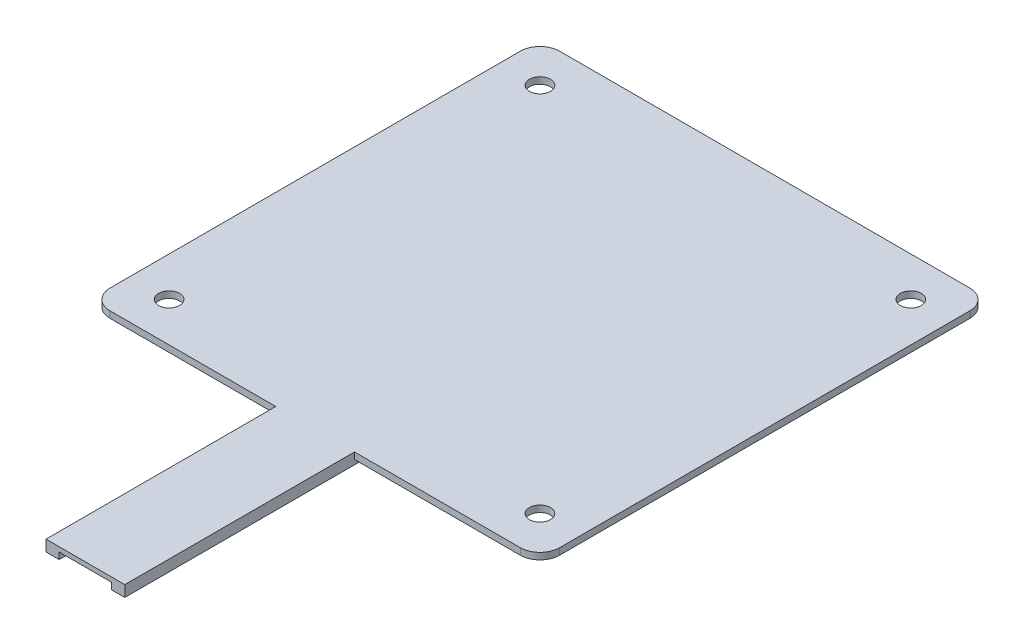
from build123d import *

# Parameters (mm, degrees)
BOSS_EXTRUDE1_DEPTH = 0.5
BOSS_EXTRUDE2_DEPTH = 1.2
SKETCH3_W           = 8
SKETCH3_H           = 2
CUT_EXTRUDE1_DEPTH  = 1
BOSS_EXTRUDE3_DEPTH = 1
FILLET1_R           = 3
SKETCH5_R           = 1.6
CUT_EXTRUDE2_DEPTH  = 1


with BuildPart() as part:
    # Sketch1 → Boss-Extrude1 (new body)
    with BuildSketch(Plane(origin=(0, 0, 0), x_dir=(1, 0, 0), z_dir=(0, 1, 0))):
        with BuildLine():
            Line((-20.743902439, 24.603658537), (27.756097561, 24.603658537))
            Line((27.756097561, 24.603658537), (27.756097561, -23.896341463))
            Line((27.756097561, -23.896341463), (12.506097561, -23.896341463))
            ThreePointArc((12.506097561, -23.896341463), (10.384777217, -24.77502112), (9.506097561, -26.896341463))
            Line((9.506097561, -26.896341463), (9.506097561, -68.896341463))
            Line((9.506097561, -68.896341463), (-2.493902439, -68.896341463))
            Line((-2.493902439, -68.896341463), (-2.493902439, -26.896341463))
            ThreePointArc((-2.493902439, -26.896341463), (-3.372582095, -24.77502112), (-5.493902439, -23.896341463))
            Line((-5.493902439, -23.896341463), (-20.743902439, -23.896341463))
            Line((-20.743902439, -23.896341463), (-20.743902439, 24.603658537))
        make_face()
        with BuildLine():
            Line((-18.743902439, 22.603658537), (25.756097561, 22.603658537))
            Line((25.756097561, 22.603658537), (25.756097561, -21.896341463))
            Line((25.756097561, -21.896341463), (12.506097561, -21.896341463))
            ThreePointArc((12.506097561, -21.896341463), (8.970563655, -23.360807557), (7.506097561, -26.896341463))
            Line((7.506097561, -26.896341463), (7.506097561, -66.896341463))
            Line((7.506097561, -66.896341463), (-0.493902439, -66.896341463))
            Line((-0.493902439, -66.896341463), (-0.493902439, -26.896341463))
            ThreePointArc((-0.493902439, -26.896341463), (-1.958368533, -23.360807557), (-5.493902439, -21.896341463))
            Line((-5.493902439, -21.896341463), (-18.743902439, -21.896341463))
            Line((-18.743902439, -21.896341463), (-18.743902439, 22.603658537))
        make_face(mode=Mode.SUBTRACT)
    extrude(amount=BOSS_EXTRUDE1_DEPTH)

    # Sketch2 → Boss-Extrude2 (add)
    with BuildSketch(Plane(origin=(0, 0.5, 0), x_dir=(1, 0, 0), z_dir=(0, 1, 0))):
        with BuildLine():
            Line((-20.743902439, 24.603658537), (-20.743902439, -23.896341463))
            Line((-20.743902439, -23.896341463), (-5.493902439, -23.896341463))
            ThreePointArc((-5.493902439, -23.896341463), (-3.372582095, -24.77502112), (-2.493902439, -26.896341463))
            Line((-2.493902439, -26.896341463), (-2.493902439, -68.896341463))
            Line((-2.493902439, -68.896341463), (9.506097561, -68.896341463))
            Line((9.506097561, -68.896341463), (9.506097561, -26.896341463))
            ThreePointArc((9.506097561, -26.896341463), (10.384777217, -24.77502112), (12.506097561, -23.896341463))
            Line((12.506097561, -23.896341463), (27.756097561, -23.896341463))
            Line((27.756097561, -23.896341463), (27.756097561, 24.603658537))
            Line((27.756097561, 24.603658537), (-20.743902439, 24.603658537))
        make_face()
    extrude(amount=BOSS_EXTRUDE2_DEPTH)

    # Sketch3 → Cut-Extrude1 (cut)
    with BuildSketch(Plane.XZ):
        with Locations((3.506097561, 67.896341463)):
            Rectangle(SKETCH3_W, SKETCH3_H)
    extrude(amount=-CUT_EXTRUDE1_DEPTH, mode=Mode.SUBTRACT)

    # Sketch4 → Boss-Extrude3 (add)
    with BuildSketch(Plane(origin=(0, 1.7, 0), x_dir=(1, 0, 0), z_dir=(0, 1, 0))):
        Polygon((-12.493902439, -33.896341463), (19.506097561, -33.896341463), (37.756097561, -33.896341463), (37.756097561, 34.603658537), (-30.743902439, 34.603658537), (-30.743902439, -33.896341463), align=None)
    extrude(amount=-BOSS_EXTRUDE3_DEPTH)

    # Fillet1
    fillet1_edges = [part.edges().sort_by_distance(p)[0] for p in [
        (37.756097561, 1.2, 33.896341463),
        (37.756097561, 1.2, -34.603658537),
        (-30.743902439, 1.2, 33.896341463),
        (-30.743902439, 1.2, -34.603658537),
    ]]
    fillet(fillet1_edges, radius=FILLET1_R)

    # Sketch5 → Cut-Extrude2 (cut)
    with BuildSketch(Plane.XZ.offset(-0.7)):
        with Locations(Location((-24.743902439, 27.896341463, 0), (0, 0, 270))):  # turned: the seam where the file's is
            Circle(SKETCH5_R)
        with Locations(Location((31.756097561, 27.896341463, 0), (0, 0, 270))):  # turned: the seam where the file's is
            Circle(SKETCH5_R)
        with Locations(Location((31.756097561, -28.603658537, 0), (0, 0, 270))):  # turned: the seam where the file's is
            Circle(SKETCH5_R)
        with Locations(Location((-24.743902439, -28.603658537, 0), (0, 0, 270))):  # turned: the seam where the file's is
            Circle(SKETCH5_R)
    extrude(amount=-CUT_EXTRUDE2_DEPTH, mode=Mode.SUBTRACT)


solid = part.part
